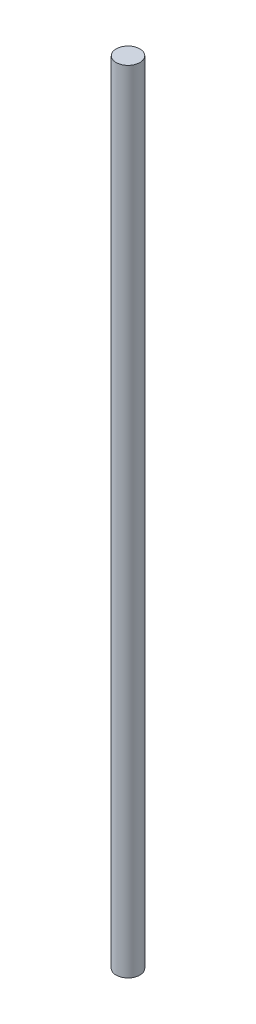
from build123d import *

# Parameters (mm, degrees)
SKETCH1_R           = 6
BOSS_EXTRUDE1_DEPTH = 400


with BuildPart() as part:
    # Sketch1 → Boss-Extrude1 (new body)
    with BuildSketch(Plane(origin=(0, 0, 0), x_dir=(1, 0, 0), z_dir=(0, 1, 0))):
        Circle(SKETCH1_R)
    extrude(amount=BOSS_EXTRUDE1_DEPTH)


solid = part.part
